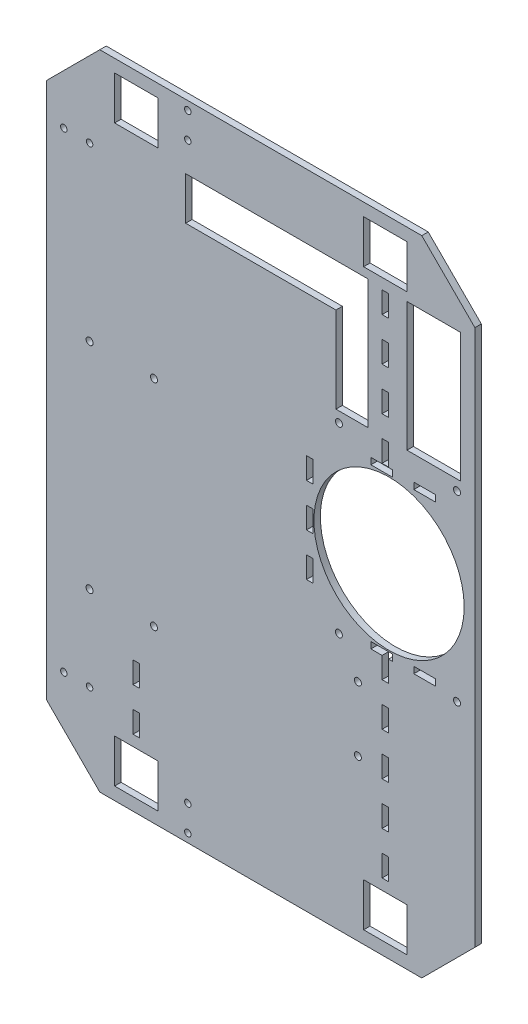
from build123d import *

# Parameters (mm, degrees)
BASE_DEPTH                      = 3
ESQUISSE3_W                     = 20.2
ESQUISSE3_H                     = 20.2
ENL_V_MAT_EXTRU_1_DEPTH         = 4
R_P_TITION_LIN_AIRE1_COUNT      = 2
R_P_TITION_LIN_AIRE1_PITCH      = 267.5
R_P_TITION_LIN_AIRE1_COUNT_DIR2 = 2
R_P_TITION_LIN_AIRE1_PITCH_DIR2 = 116
ESQUISSE4_R                     = 35
ENL_V_MAT_EXTRU_2_DEPTH         = 4
ESQUISSE5_R                     = 1.625
ENL_V_MAT_EXTRU_3_DEPTH         = 3
R_P_TITION_LIN_AIRE2_COUNT      = 2
R_P_TITION_LIN_AIRE2_PITCH      = 85
R_P_TITION_LIN_AIRE2_COUNT_DIR2 = 2
R_P_TITION_LIN_AIRE2_PITCH_DIR2 = 55
ENL_V_MAT_EXTRU_4_REACH         = 5
ESQUISSE6_W                     = 25
ESQUISSE6_H                     = 60
ESQUISSE8_R                     = 1.5
TROUS_DEGUISEMENT_DEPTH         = 5
SKETCH1_W                       = 3
SKETCH1_H                       = 10
CUT_EXTRUDE1_DEPTH              = 4
LPATTERN1_COUNT                 = 5
LPATTERN1_PITCH                 = 20
SKETCH2_W                       = 3
SKETCH2_H                       = 10
CUT_EXTRUDE2_DEPTH              = 4
LPATTERN2_COUNT                 = 2
LPATTERN2_PITCH                 = 20
SKETCH3_W                       = 3
SKETCH3_H                       = 10
CUT_EXTRUDE3_DEPTH              = 4
LPATTERN3_COUNT                 = 4
LPATTERN3_PITCH                 = 20
ESQUISSE9_R                     = 1.625
ENL_V_MAT_EXTRU_5_DEPTH         = 10
ESQUISSE10_W                    = 10
ESQUISSE10_H                    = 3
ENL_V_MAT_EXTRU_6_DEPTH         = 3
ESQUISSE11_W                    = 3
ESQUISSE11_H                    = 10
ENL_V_MAT_EXTRU_7_DEPTH         = 3


with BuildPart() as part:
    # Esquisse1 → Base (new body)
    with BuildSketch(Plane.XY):
        Polygon((24.748737342, 24.748737342), (0, 0), (-150, 0), (-174.748737342, 24.748737342), (-174.748737342, 274.748737342), (-150, 299.497474683), (0, 299.497474683), (24.748737342, 274.748737342), align=None)
    extrude(amount=BASE_DEPTH)

    # Esquisse3 → Enlèv. mat.-Extru.1 (cut, through all)
    with BuildSketch(Plane.XY.offset(3)):
        with Locations((-132.998737342, 16)):
            Rectangle(ESQUISSE3_W, ESQUISSE3_H)
    enl_v_mat_extru_1 = extrude(amount=-ENL_V_MAT_EXTRU_1_DEPTH, mode=Mode.SUBTRACT)

    # Répétition linéaire1: Enl_v. mat.-Extru.1 2 × 2
    with Locations(*[(j * R_P_TITION_LIN_AIRE1_PITCH_DIR2, i * R_P_TITION_LIN_AIRE1_PITCH, 0) for i in range(R_P_TITION_LIN_AIRE1_COUNT) for j in range(R_P_TITION_LIN_AIRE1_COUNT_DIR2) if (i, j) != (0, 0)]):
        add(enl_v_mat_extru_1, mode=Mode.SUBTRACT)

    # Esquisse4 → Enlèv. mat.-Extru.2 (cut, through all)
    with BuildSketch(Plane.XY.offset(3)):
        with Locations((-15.251262658, 159.497474683)):
            Circle(ESQUISSE4_R)
    extrude(amount=-ENL_V_MAT_EXTRU_2_DEPTH, mode=Mode.SUBTRACT)

    # Esquisse5 → Enlèv. mat.-Extru.3 (cut)
    with BuildSketch(Plane.XY.offset(3)):
        with Locations((16.398737342, 119.65)):
            Circle(ESQUISSE5_R)
    enl_v_mat_extru_3 = extrude(amount=-ENL_V_MAT_EXTRU_3_DEPTH, mode=Mode.SUBTRACT)

    # Répétition linéaire2: Enl_v. mat.-Extru.3 2 × 2
    with Locations(*[(-j * R_P_TITION_LIN_AIRE2_PITCH_DIR2, i * R_P_TITION_LIN_AIRE2_PITCH, 0) for i in range(R_P_TITION_LIN_AIRE2_COUNT) for j in range(R_P_TITION_LIN_AIRE2_COUNT_DIR2) if (i, j) != (0, 0)]):
        add(enl_v_mat_extru_3, mode=Mode.SUBTRACT)

    # Esquisse6 → Enlèv. mat.-Extru.4 (cut, up to next)
    with BuildSketch(Plane.XY.offset(3), mode=Mode.PRIVATE) as enl_v_mat_extru_4_sk1:
        Polygon((-110, 269.497474683), (-40, 269.497474683), (-25, 269.497474683), (-25, 209.497474683), (-40, 209.497474683), (-40, 249.497474683), (-110, 249.497474683), align=None)
    enl_v_mat_extru_4_tool1 = extrude(enl_v_mat_extru_4_sk1.sketch, amount=-ENL_V_MAT_EXTRU_4_REACH, mode=Mode.PRIVATE) & part.part
    add(enl_v_mat_extru_4_tool1.solids().sort_by_distance((-58.369565, 251.671388, 3))[0], mode=Mode.SUBTRACT)
    # Esquisse6 → Enlèv. mat.-Extru.4 (cut, up to next)
    with BuildSketch(Plane.XY.offset(3), mode=Mode.PRIVATE) as enl_v_mat_extru_4_sk2:
        with Locations((5.601262658, 239.497474683)):
            Rectangle(ESQUISSE6_W, ESQUISSE6_H)
    enl_v_mat_extru_4_tool2 = extrude(enl_v_mat_extru_4_sk2.sketch, amount=-ENL_V_MAT_EXTRU_4_REACH, mode=Mode.PRIVATE) & part.part
    add(enl_v_mat_extru_4_tool2.solids().sort_by_distance((5.601263, 239.497475, 3))[0], mode=Mode.SUBTRACT)

    # Esquisse8 → Trous deguisement (cut)
    with BuildSketch(Plane.XY.offset(3)):
        with Locations((-109, 295.497474683)):
            Circle(ESQUISSE8_R)
        with Locations((-109, 283.497474683)):
            Circle(ESQUISSE8_R)
        with Locations((-166.748737342, 259.497474683)):
            Circle(ESQUISSE8_R)
        with Locations((-154.748737342, 259.497474683)):
            Circle(ESQUISSE8_R)
        with Locations((-109, 16)):
            Circle(ESQUISSE8_R)
        with Locations((-109, 4)):
            Circle(ESQUISSE8_R)
        with Locations((-154.748737342, 40)):
            Circle(ESQUISSE8_R)
        with Locations((-166.748737342, 40)):
            Circle(ESQUISSE8_R)
    extrude(amount=-TROUS_DEGUISEMENT_DEPTH, mode=Mode.SUBTRACT)

    # Sketch1 → Cut-Extrude1 (cut, through all)
    with BuildSketch(Plane.XY.offset(3)):
        with Locations((-16.998737342, 36.1)):
            Rectangle(SKETCH1_W, SKETCH1_H)
    cut_extrude1 = extrude(amount=-CUT_EXTRUDE1_DEPTH, mode=Mode.SUBTRACT)

    # LPattern1: Cut-Extrude1 ×5
    with Locations(*[(0, i * LPATTERN1_PITCH, 0) for i in range(1, LPATTERN1_COUNT)]):
        add(cut_extrude1, mode=Mode.SUBTRACT)

    # Sketch2 → Cut-Extrude2 (cut, through all)
    with BuildSketch(Plane.XY.offset(3)):
        with Locations((-132.998737342, 36.1)):
            Rectangle(SKETCH2_W, SKETCH2_H)
    cut_extrude2 = extrude(amount=-CUT_EXTRUDE2_DEPTH, mode=Mode.SUBTRACT)

    # LPattern2: Cut-Extrude2 ×2
    with Locations(*[(0, i * LPATTERN2_PITCH, 0) for i in range(1, LPATTERN2_COUNT)]):
        add(cut_extrude2, mode=Mode.SUBTRACT)

    # Sketch3 → Cut-Extrude3 (cut, through all)
    with BuildSketch(Plane.XY.offset(3)):
        with Locations((-16.998737342, 263.4)):
            Rectangle(SKETCH3_W, SKETCH3_H)
    cut_extrude3 = extrude(amount=-CUT_EXTRUDE3_DEPTH, mode=Mode.SUBTRACT)

    # LPattern3: Cut-Extrude3 ×4
    with Locations(*[(0, -i * LPATTERN3_PITCH, 0) for i in range(1, LPATTERN3_COUNT)]):
        add(cut_extrude3, mode=Mode.SUBTRACT)

    # Esquisse9 → Enlèv. mat.-Extru.5 (cut)
    with BuildSketch(Plane.XY.offset(3)):
        with Locations((-154.748737342, 179.497474683)):
            Circle(ESQUISSE9_R)
        with Locations((-124.748737342, 179.497474683)):
            Circle(ESQUISSE9_R)
        with Locations((-154.748737342, 79.497474683)):
            Circle(ESQUISSE9_R)
        with Locations((-124.748737342, 79.497474683)):
            Circle(ESQUISSE9_R)
        with Locations((-29.748737342, 74.65)):
            Circle(ESQUISSE9_R)
        with Locations((-29.748737342, 104.65)):
            Circle(ESQUISSE9_R)
    extrude(amount=-ENL_V_MAT_EXTRU_5_DEPTH, mode=Mode.SUBTRACT)

    # Esquisse10 → Enlèv. mat.-Extru.6 (cut)
    with BuildSketch(Plane.XY.offset(3)):
        with Locations((1.298737342, 122.4)):
            Rectangle(ESQUISSE10_W, ESQUISSE10_H)
        with Locations((-18.701262658, 122.4)):
            Rectangle(ESQUISSE10_W, ESQUISSE10_H)
        with Locations((-18.701262658, 196.697474683)):
            Rectangle(ESQUISSE10_W, ESQUISSE10_H)
        with Locations((1.298737342, 196.697474683)):
            Rectangle(ESQUISSE10_W, ESQUISSE10_H)
    extrude(amount=-ENL_V_MAT_EXTRU_6_DEPTH, mode=Mode.SUBTRACT)

    # Esquisse11 → Enlèv. mat.-Extru.7 (cut)
    with BuildSketch(Plane.XY.offset(3)):
        with Locations((-52.201262658, 158.9)):
            Rectangle(ESQUISSE11_W, ESQUISSE11_H)
        with Locations((-52.201262658, 138.9)):
            Rectangle(ESQUISSE11_W, ESQUISSE11_H)
        with Locations((-52.201262658, 178.9)):
            Rectangle(ESQUISSE11_W, ESQUISSE11_H)
    extrude(amount=-ENL_V_MAT_EXTRU_7_DEPTH, mode=Mode.SUBTRACT)


solid = part.part
